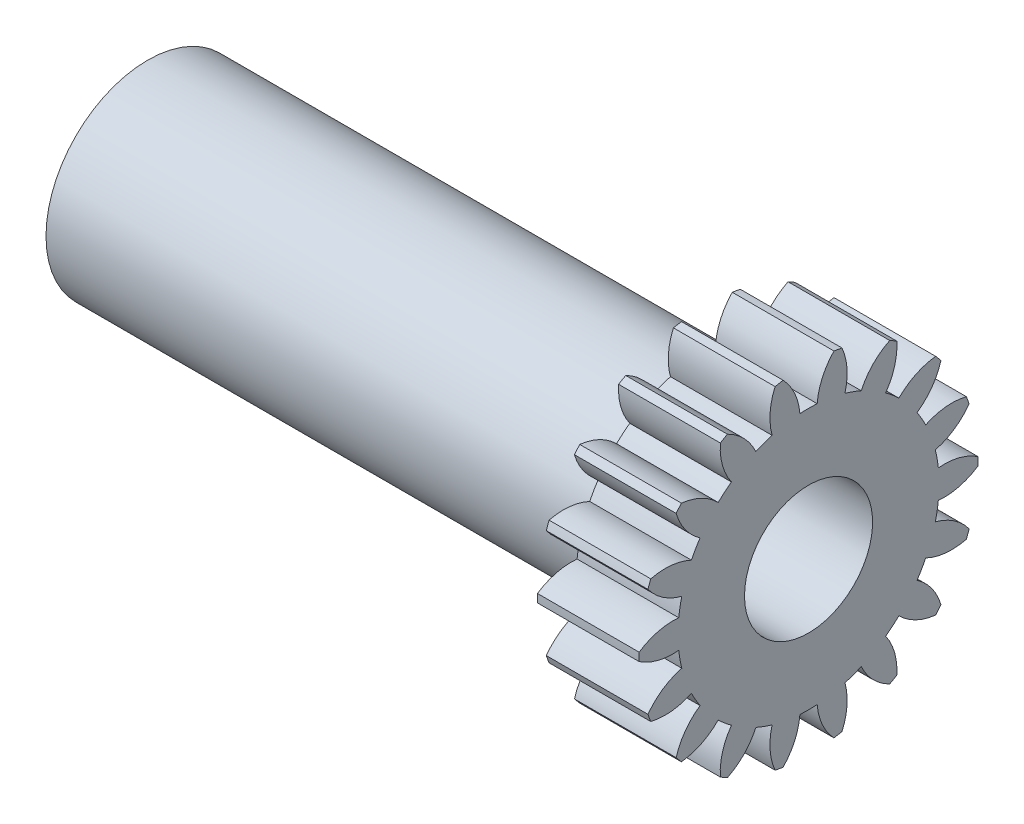
from build123d import *

# Parameters (mm, degrees)
BASPROSKE_W         = 3.175
BASPROSKE_H         = 5.291666667
TOOTHCUT_DEPTH      = 9.129212583
TEETHCUTS_COUNT     = 18
TEETHCUTS_ANGLE     = 340
SKETCH2_R           = 2
CUT_EXTRUDE3_DEPTH  = 9.090468526
BOSS_EXTRUDE1_START = 17.4625
SKETCH2_3_R         = 3.175
SKETCH2_3_R_2       = 2
BOSS_EXTRUDE1_DEPTH = 17.4625


with BuildPart() as part:
    # BasProSke → Base-Revolve (revolve)
    with BuildSketch(Plane(origin=(0, 0, 0), x_dir=(1, 0, 0), z_dir=(0, 1, 0))):
        with Locations((1.5875, 2.645833334)):
            Rectangle(BASPROSKE_W, BASPROSKE_H)
    revolve(axis=Axis((-10, 0, 0), (1, 0, 0)))

    # TooCutSke → ToothCut (cut, through all)
    with BuildSketch(Plane(origin=(0, 0, 0), x_dir=(0, 0, -1), z_dir=(1, 0, 0))):
        with BuildLine():
            ThreePointArc((0.270003318, 4.067748898), (0, 4.0767), (-0.270003318, 4.067748898))
            ThreePointArc((-0.270003318, 4.067748898), (-0.437425956, 4.709129954), (-0.814487039, 5.254313352))
            ThreePointArc((-0.814487039, 5.254313352), (0, 5.317066667), (0.814487039, 5.254313352))
            ThreePointArc((0.814487039, 5.254313352), (0.437425956, 4.709129954), (0.270003318, 4.067748898))
        make_face()
    toothcut = extrude(amount=TOOTHCUT_DEPTH, mode=Mode.SUBTRACT)

    # TeethCuts: ToothCut ×18 about axis
    teethcuts_axis = Axis((-10, 0, 0), (1, 0, 0))
    for i in range(1, TEETHCUTS_COUNT):
        add(toothcut.rotate(teethcuts_axis, i * TEETHCUTS_ANGLE / (TEETHCUTS_COUNT - 1)), mode=Mode.SUBTRACT)

    # Sketch2 → Cut-Extrude3 (cut, through all)
    with BuildSketch(Plane.ZY):
        Circle(SKETCH2_R)
    extrude(amount=-CUT_EXTRUDE3_DEPTH, mode=Mode.SUBTRACT)

    # Sketch2_3 → Boss-Extrude1 (add)
    with BuildSketch(Plane.ZY.offset(BOSS_EXTRUDE1_START)):
        Circle(SKETCH2_3_R)
        Circle(SKETCH2_3_R_2, mode=Mode.SUBTRACT)
    extrude(amount=-BOSS_EXTRUDE1_DEPTH)


solid = part.part
